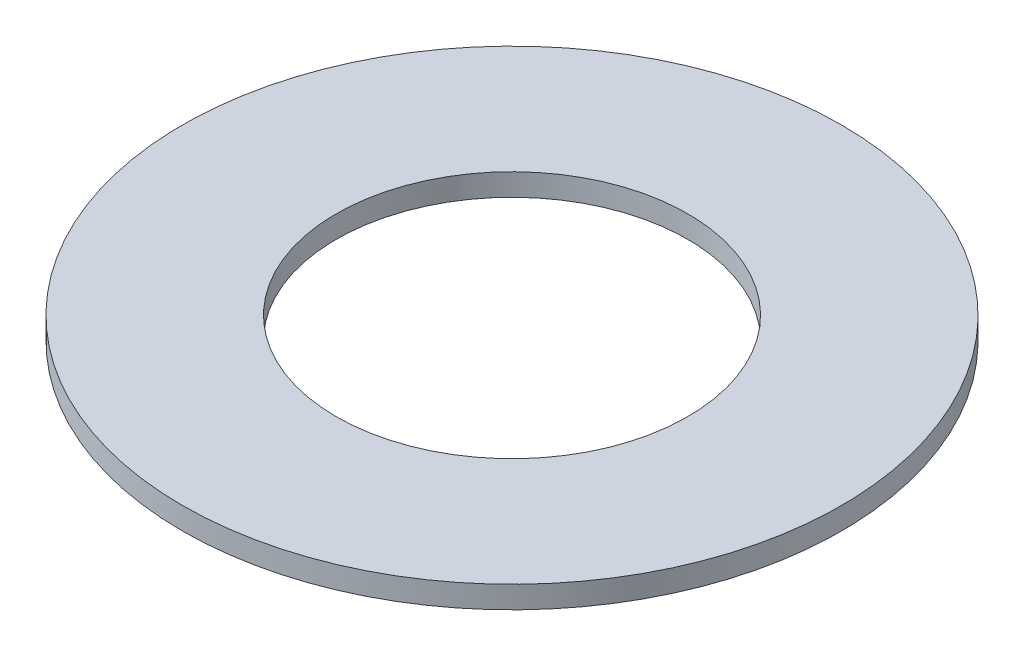
from build123d import *

# Parameters (mm, degrees)
SKETCH1_R           = 11.90625
SKETCH1_R_2         = 6.35
BOSS_EXTRUDE1_DEPTH = 0.8001


with BuildPart() as part:
    # Sketch1 → Boss-Extrude1 (new body)
    with BuildSketch(Plane(origin=(0, 0, 0), x_dir=(1, 0, 0), z_dir=(0, 1, 0))):
        Circle(SKETCH1_R)
        Circle(SKETCH1_R_2, mode=Mode.SUBTRACT)
    extrude(amount=BOSS_EXTRUDE1_DEPTH)


solid = part.part
